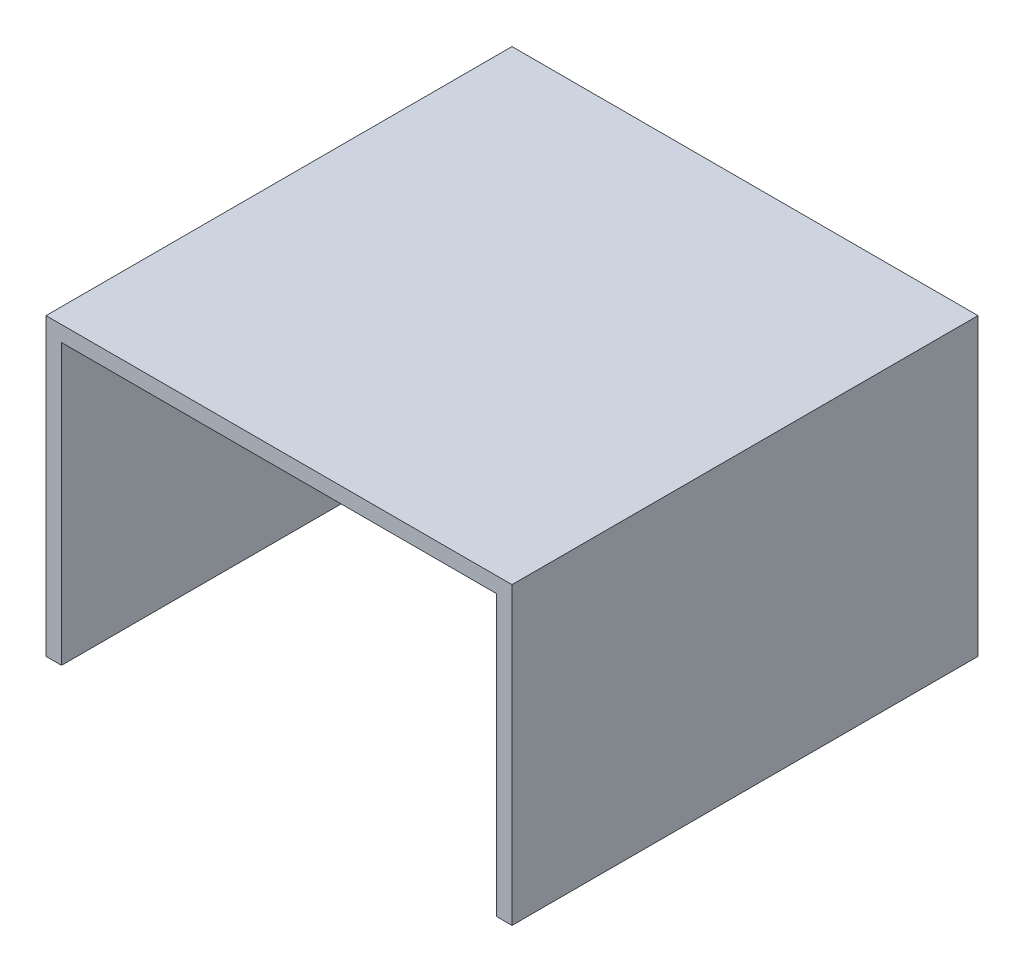
from build123d import *

# Parameters (mm, degrees)
SKETCH1_W           = 60
SKETCH1_H           = 60
BOSS_EXTRUDE1_DEPTH = 2
SKETCH2_W           = 2
SKETCH2_H           = 60
BOSS_EXTRUDE2_DEPTH = 36


with BuildPart() as part:
    # Sketch1 → Boss-Extrude1 (new body)
    with BuildSketch(Plane(origin=(0, 0, 0), x_dir=(1, 0, 0), z_dir=(0, 1, 0))):
        with Locations((4.971289332, -16.330275229)):
            Rectangle(SKETCH1_W, SKETCH1_H)
    extrude(amount=BOSS_EXTRUDE1_DEPTH)

    # Sketch2 → Boss-Extrude2 (add)
    with BuildSketch(Plane.XZ):
        with Locations((33.971289332, 16.330275229)):
            Rectangle(SKETCH2_W, SKETCH2_H)
        with Locations((-24.028710668, 16.330275229)):
            Rectangle(SKETCH2_W, SKETCH2_H)
    extrude(amount=BOSS_EXTRUDE2_DEPTH)


solid = part.part
